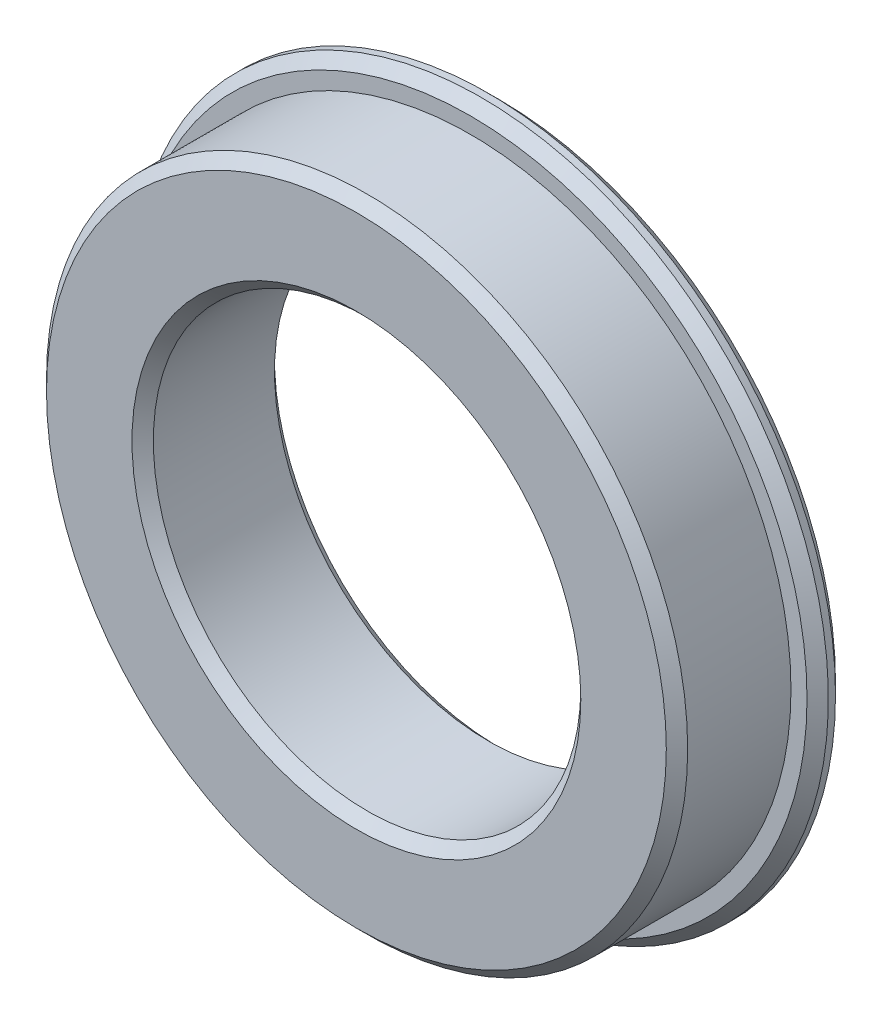
from build123d import *

# Parameters (mm, degrees)
SKETCH_1_R      = 9
SKETCH_1_R_2    = 6
EXTRUDE_1_DEPTH = 4
SKETCH_2_R      = 9.75
SKETCH_2_R_2    = 9
EXTRUDE_2_DEPTH = 0.8
CHAMFER_1_SIZE  = 0.3


with BuildPart() as part:
    # 草图1 → 凸台-拉伸1 (new body)
    with BuildSketch(Plane.XY):
        Circle(SKETCH_1_R)
        Circle(SKETCH_1_R_2, mode=Mode.SUBTRACT)
    extrude(amount=EXTRUDE_1_DEPTH)

    # 草图2 → 凸台-拉伸2 (add)
    with BuildSketch(Plane(origin=(0, 0, 0), x_dir=(-1, 0, 0), z_dir=(0, 0, -1))):
        Circle(SKETCH_2_R)
        Circle(SKETCH_2_R_2, mode=Mode.SUBTRACT)
    extrude(amount=-EXTRUDE_2_DEPTH)

    # 倒角1
    chamfer_1_edges = [part.edges().sort_by_distance(p)[0] for p in [
        (9.75, 0, 0.8),
        (9.75, 0, 0),
        (-9, 0, 4),
        (-6, 0, 0),
        (-6, 0, 4),
    ]]
    chamfer(chamfer_1_edges, length=CHAMFER_1_SIZE)


solid = part.part
